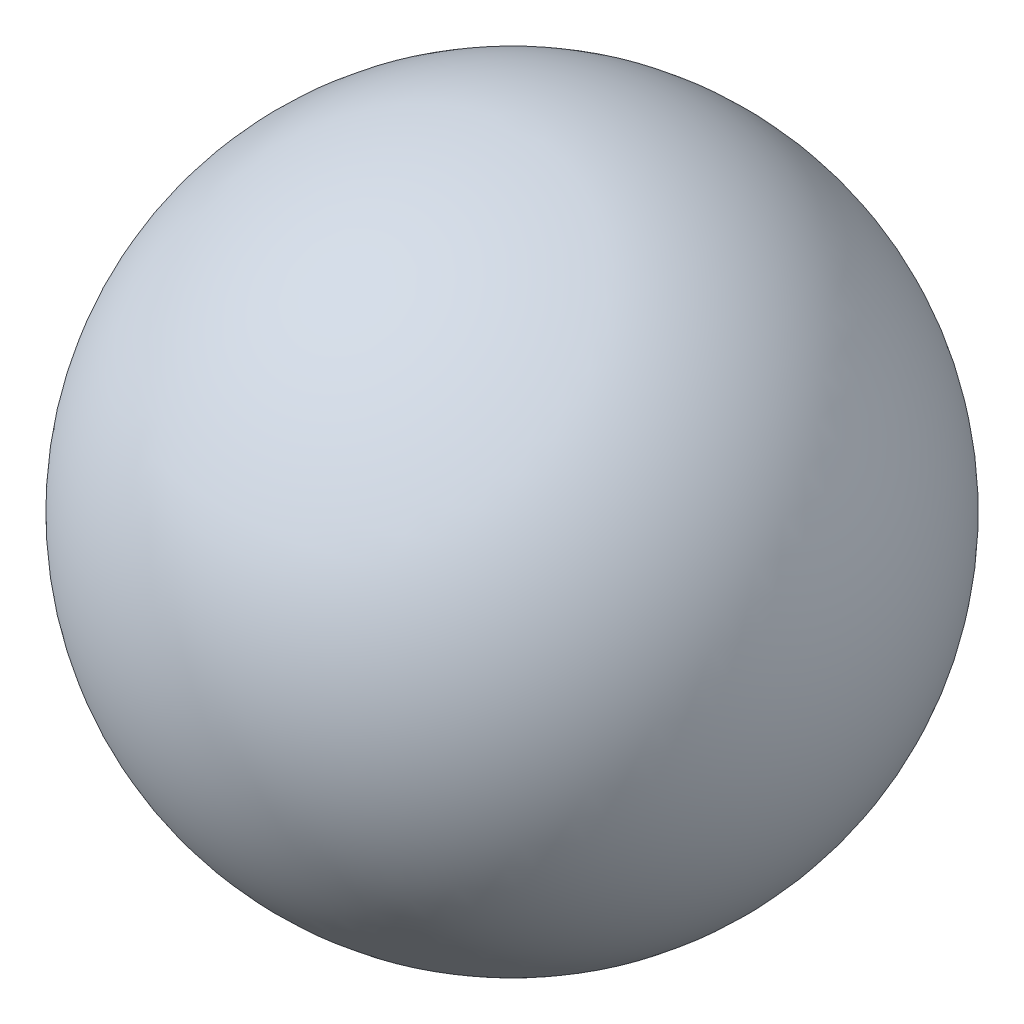
from build123d import *


with BuildPart() as part:
    # Sketch1 → Revolve1 (revolve)
    with BuildSketch(Plane.XY):
        with BuildLine():
            Line((0, 100), (0, -100))
            ThreePointArc((0, -100), (-100, 0), (0, 100))
        make_face()
    revolve(axis=Axis((0, 100, 0), (0, -1, 0)))


solid = part.part
